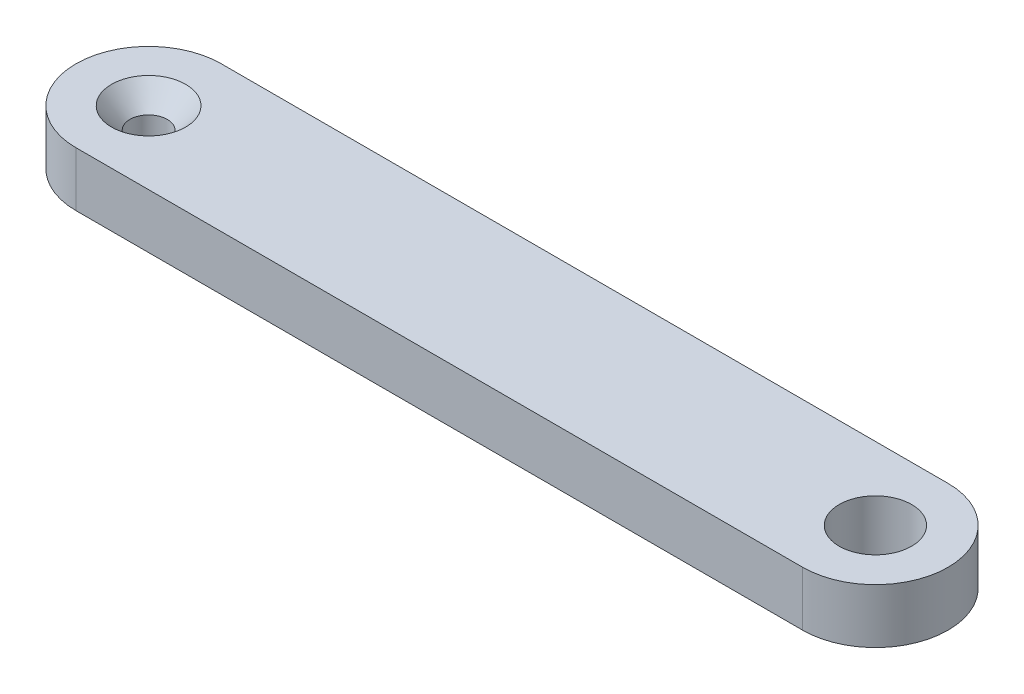
from build123d import *

# Parameters (mm, degrees)
BOSS_EXTRUDE2_DEPTH                               = 4.7625
SKETCH2_R                                         = 3.1623
CUT_EXTRUDE1_DEPTH                                = 5.7625
CSK_FOR_4_FLAT_HEAD_SOCKET_CAP_SCREW1_D           = 3.2639
CSK_FOR_4_FLAT_HEAD_SOCKET_CAP_SCREW1_CSINK_D     = 6.477
CSK_FOR_4_FLAT_HEAD_SOCKET_CAP_SCREW1_CSINK_ANGLE = 82


with BuildPart() as part:
    # Sketch1 → Boss-Extrude2 (new body)
    with BuildSketch(Plane(origin=(0, 0, 0), x_dir=(1, 0, 0), z_dir=(0, 1, 0))):
        with BuildLine():
            Line((-63.5, 6.35), (0, 6.35))
            ThreePointArc((0, 6.35), (6.35, 0), (0, -6.35))
            Line((0, -6.35), (-63.5, -6.35))
            ThreePointArc((-63.5, -6.35), (-69.85, 0), (-63.5, 6.35))
        make_face()
    extrude(amount=BOSS_EXTRUDE2_DEPTH)

    # Sketch2 → Cut-Extrude1 (cut, through all)
    with BuildSketch(Plane(origin=(0, 4.7625, 0), x_dir=(1, 0, 0), z_dir=(0, 1, 0))):
        Circle(SKETCH2_R)
    extrude(amount=-CUT_EXTRUDE1_DEPTH, mode=Mode.SUBTRACT)

    # CSK for #4 Flat Head Socket Cap Screw1 (through all)
    with Locations(Plane(origin=(0, 4.7625, 0), x_dir=(1, 0, 0), z_dir=(0, 1, 0))):
        with Locations((-63.5, 0)):
            CounterSinkHole(CSK_FOR_4_FLAT_HEAD_SOCKET_CAP_SCREW1_D / 2, CSK_FOR_4_FLAT_HEAD_SOCKET_CAP_SCREW1_CSINK_D / 2, counter_sink_angle=CSK_FOR_4_FLAT_HEAD_SOCKET_CAP_SCREW1_CSINK_ANGLE)


solid = part.part
